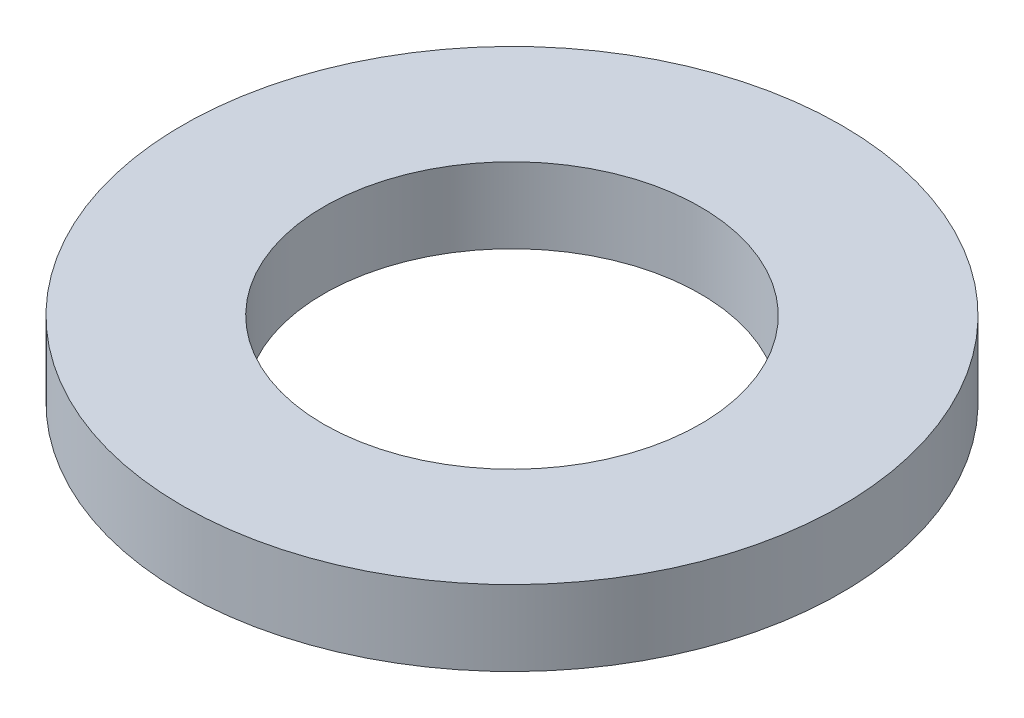
from build123d import *

# Parameters (mm, degrees)
SKETCH1_R           = 4.375
SKETCH1_R_2         = 2.5
BOSS_EXTRUDE1_DEPTH = 1


with BuildPart() as part:
    # Sketch1 → Boss-Extrude1 (new body)
    with BuildSketch(Plane(origin=(0, 0, 0), x_dir=(1, 0, 0), z_dir=(0, 1, 0))):
        Circle(SKETCH1_R)
        Circle(SKETCH1_R_2, mode=Mode.SUBTRACT)
    extrude(amount=BOSS_EXTRUDE1_DEPTH)


solid = part.part
